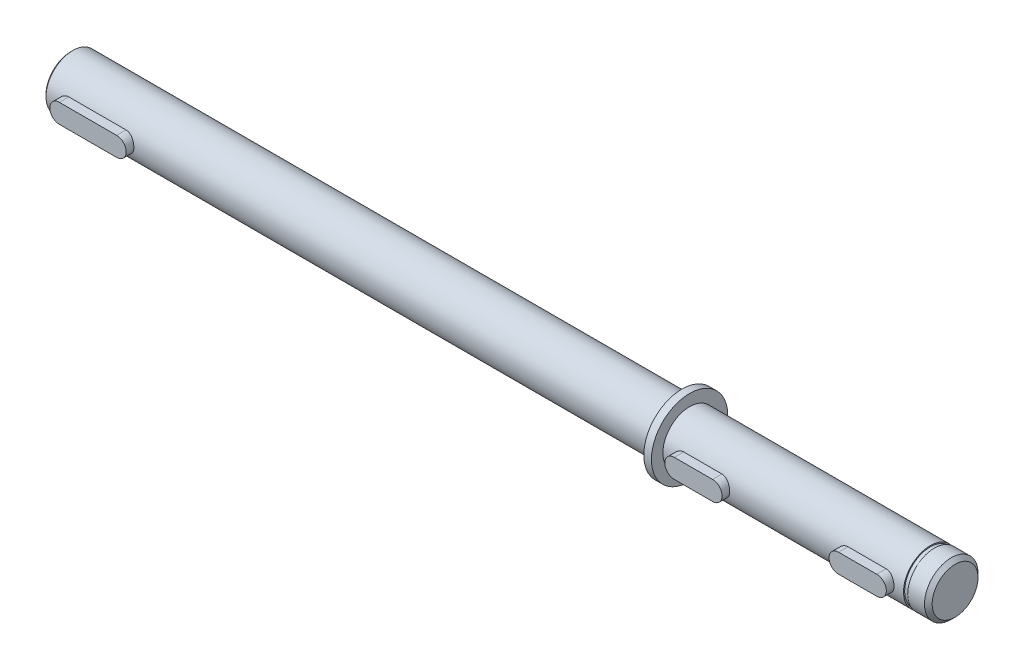
from build123d import *

# Parameters (mm, degrees)
EXTRUDE_1_DEPTH        = 9
SKETCH_3_R             = 15
CUT_EXTRUDE_1_DEPTH    = 26.5
HOLE_WIZARD_M6_1_D     = 5
HOLE_WIZARD_M6_1_DEPTH = 17
HOLE_WIZARD_M6_1_TIP   = 1.502151548
CHAMFER_1_SIZE         = 1
SKETCH_6_W             = 1.1
SKETCH_6_H             = 0.3


with BuildPart() as part:
    # 草图1 → 旋转1 (revolve)
    with BuildSketch(Plane.XY):
        Polygon((-129, 0), (129, 0), (129, 6), (128, 7), (33, 7), (33, 10), (31, 10), (31, 7), (-128.5, 7), (-129, 6.5), align=None)
    revolve(axis=Axis((-129, 0, 0), (1, 0, 0)))

    # 草图2 → 凸台-拉伸1 (add)
    with BuildSketch(Plane.XY):
        with BuildLine():
            ThreePointArc((-108, 2.5), (-105.5, 0), (-108, -2.5))
            Line((-108, -2.5), (-123, -2.5))
            ThreePointArc((-123, -2.5), (-125.5, 0), (-123, 2.5))
            Line((-123, 2.5), (-108, 2.5))
        make_face()
        with BuildLine():
            Line((38, -2.5), (48, -2.5))
            ThreePointArc((48, -2.5), (50.5, 0), (48, 2.5))
            Line((48, 2.5), (38, 2.5))
            ThreePointArc((38, 2.5), (35.5, 0), (38, -2.5))
        make_face()
        with BuildLine():
            Line((123, 2.5), (108, 2.5))
            ThreePointArc((108, 2.5), (105.5, 0), (108, -2.5))
            Line((108, -2.5), (123, -2.5))
            ThreePointArc((123, -2.5), (125.5, 0), (123, 2.5))
        make_face()
        with BuildLine():
            Line((81, -2.5), (91, -2.5))
            ThreePointArc((91, -2.5), (93.5, 0), (91, 2.5))
            Line((91, 2.5), (81, 2.5))
            ThreePointArc((81, 2.5), (78.5, 0), (81, -2.5))
        make_face()
    extrude(amount=EXTRUDE_1_DEPTH)

    # 草图3 → 切除-拉伸1 (cut)
    with BuildSketch(Plane(origin=(129, 0, 0), x_dir=(0, 0, -1), z_dir=(1, 0, 0))):
        Circle(SKETCH_3_R)
    extrude(amount=-CUT_EXTRUDE_1_DEPTH, mode=Mode.SUBTRACT)

    # M6 螺纹孔1
    with Locations(Plane.ZY.offset(129)):
        with Locations((0, 0)):
            Hole(HOLE_WIZARD_M6_1_D / 2, depth=HOLE_WIZARD_M6_1_DEPTH)
            with Locations((0, 0, -(HOLE_WIZARD_M6_1_DEPTH + HOLE_WIZARD_M6_1_TIP / 2))):  # 118° drill point
                Cone(0, HOLE_WIZARD_M6_1_D / 2, HOLE_WIZARD_M6_1_TIP, mode=Mode.SUBTRACT)

    # 倒角1
    chamfer_1_edges = [part.edges().sort_by_distance(p)[0] for p in [
        (102.5, -7, 0),
    ]]
    chamfer(chamfer_1_edges, length=CHAMFER_1_SIZE)

    # 草图6 → 切除-旋转1 (revolve, cut)
    with BuildSketch(Plane.XY):
        with Locations((96.55, -6.85)):
            Rectangle(SKETCH_6_W, SKETCH_6_H)
    revolve(axis=Axis((0, 0, 0), (1, 0, 0)), mode=Mode.SUBTRACT)


solid = part.part
